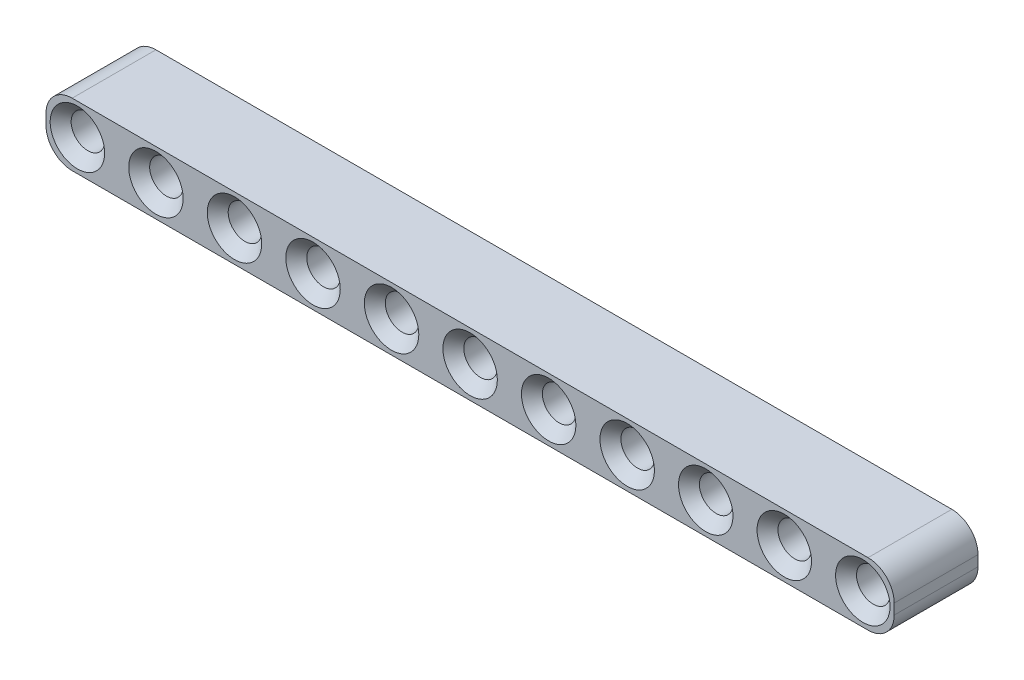
from build123d import *

# Parameters (mm, degrees)
SKETCH1_R           = 1.6
BOSS_EXTRUDE1_DEPTH = 8
CHAMFER1_SIZE       = 1


with BuildPart() as part:
    # Sketch1 → Boss-Extrude1 (new body)
    with BuildSketch(Plane.XY):
        with BuildLine():
            Line((-0.5, 3), (75.5, 3))
            ThreePointArc((75.5, 3), (77.267766953, 2.267766953), (78, 0.5))
            Line((78, 0.5), (78, -0.5))
            ThreePointArc((78, -0.5), (77.267766953, -2.267766953), (75.5, -3))
            Line((75.5, -3), (-0.5, -3))
            ThreePointArc((-0.5, -3), (-2.267766953, -2.267766953), (-3, -0.5))
            Line((-3, -0.5), (-3, 0.5))
            ThreePointArc((-3, 0.5), (-2.267766953, 2.267766953), (-0.5, 3))
        make_face()
        Circle(SKETCH1_R, mode=Mode.SUBTRACT)
        with Locations((7.5, 0)):
            Circle(SKETCH1_R, mode=Mode.SUBTRACT)
        with Locations((15, 0)):
            Circle(SKETCH1_R, mode=Mode.SUBTRACT)
        with Locations((22.5, 0)):
            Circle(SKETCH1_R, mode=Mode.SUBTRACT)
        with Locations((30, 0)):
            Circle(SKETCH1_R, mode=Mode.SUBTRACT)
        with Locations((37.5, 0)):
            Circle(SKETCH1_R, mode=Mode.SUBTRACT)
        with Locations((45, 0)):
            Circle(SKETCH1_R, mode=Mode.SUBTRACT)
        with Locations((52.5, 0)):
            Circle(SKETCH1_R, mode=Mode.SUBTRACT)
        with Locations((60, 0)):
            Circle(SKETCH1_R, mode=Mode.SUBTRACT)
        with Locations((67.5, 0)):
            Circle(SKETCH1_R, mode=Mode.SUBTRACT)
        with Locations((75, 0)):
            Circle(SKETCH1_R, mode=Mode.SUBTRACT)
    extrude(amount=BOSS_EXTRUDE1_DEPTH)

    # Chamfer1
    chamfer1_edges = [part.edges().sort_by_distance(p)[0] for p in [
        (-1.6, 0, 0),
        (-1.6, 0, 8),
        (5.9, 0, 0),
        (5.9, 0, 8),
        (13.4, 0, 0),
        (13.4, 0, 8),
        (20.9, 0, 0),
        (20.9, 0, 8),
        (28.4, 0, 0),
        (28.4, 0, 8),
        (35.9, 0, 0),
        (35.9, 0, 8),
        (43.4, 0, 0),
        (43.4, 0, 8),
        (50.9, 0, 0),
        (50.9, 0, 8),
        (58.4, 0, 0),
        (58.4, 0, 8),
        (65.9, 0, 0),
        (65.9, 0, 8),
        (73.4, 0, 0),
        (73.4, 0, 8),
    ]]
    chamfer(chamfer1_edges, length=CHAMFER1_SIZE)


solid = part.part
